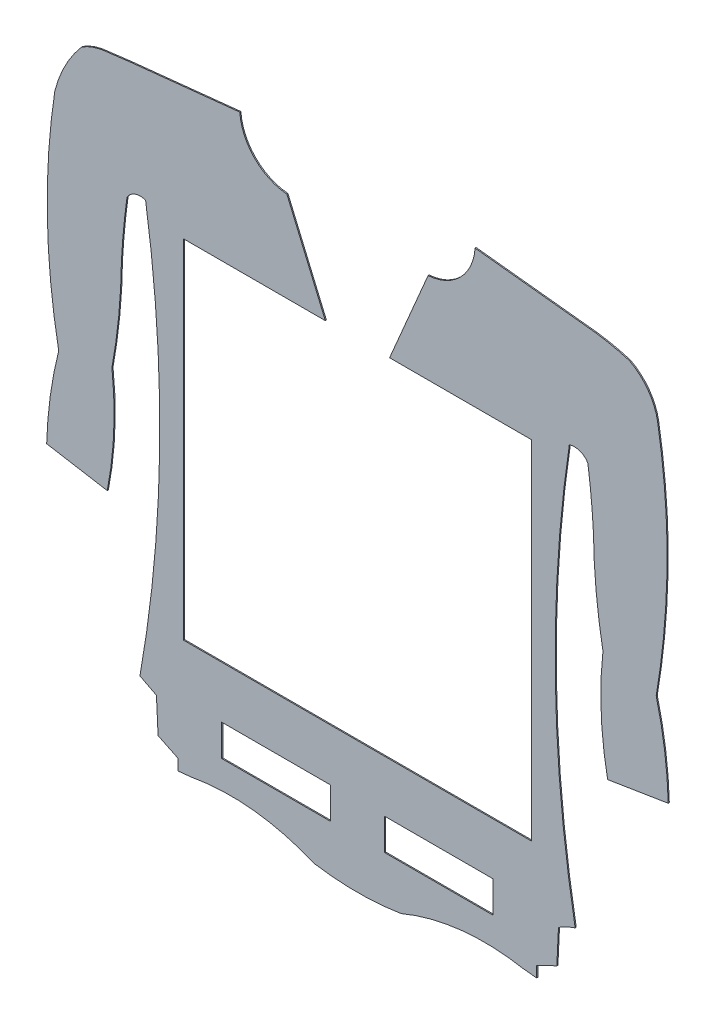
from build123d import *

# Parameters (mm, degrees)
MODEL_W                 = 10
MODEL_H                 = 2.9
SALIENTE_EXTRUIR1_DEPTH = 0.1


with BuildPart() as part:
    # Model → Saliente-Extruir1 (new body)
    with BuildSketch(Plane.XY):
        with BuildLine():
            Line((35.788328911, 21.707483708), (34.562799173, 21.581308157))
            Line((34.562799173, 21.581308157), (34.562652828, 22.581308147))
            Line((34.562652828, 22.581308147), (32.70612679, 23.481266233))
            Line((32.70612679, 23.481266233), (32.556235076, 26.619326304))
            Line((32.556235076, 26.619326304), (31.036614796, 27.404548337))
            ThreePointArc((31.036614796, 27.404548337), (32.854753025, 46.472842043), (31.55872141, 65.583722544))
            ThreePointArc((31.55872141, 65.583722544), (30.590969531, 65.595574241), (29.845859092, 64.977921752))
            ThreePointArc((29.845859092, 64.977921752), (29.533169752, 62.324588377), (29.332558898, 59.660435997))
            ThreePointArc((29.332558898, 59.660435997), (29.087424273, 55.159098423), (28.459158768, 50.695085274))
            ThreePointArc((28.459158768, 50.695085274), (28.627310402, 45.667965845), (28.027763798, 40.673894501))
            Line((28.027763798, 40.673894501), (22.450336553, 41.621102944))
            ThreePointArc((22.450336553, 41.621102944), (22.785375557, 45.632918576), (23.55872141, 49.583722544))
            ThreePointArc((23.55872141, 49.583722544), (22.508827615, 59.842451026), (23.202312308, 70.131419197))
            ThreePointArc((23.202312308, 70.131419197), (24.161095869, 72.639029062), (25.666362665, 74.861987681))
            ThreePointArc((25.666362665, 74.861987681), (26.473042164, 75.27855447), (27.341750173, 75.542384144))
            Line((27.341750173, 75.542384144), (27.561102277, 75.584512547))
            Line((27.561102277, 75.584512547), (30.155444554, 75.902266174))
            Line((30.155444554, 75.902266174), (40.23046228, 76.952955231))
            ThreePointArc((40.23046228, 76.952955231), (41.577753061, 73.95916021), (44.55872141, 72.583722544))
            Line((44.55872141, 72.583722544), (48.101813752, 64.261756561))
            Line((48.101813752, 64.261756561), (35.059978867, 64.261756561))
            Line((35.059978867, 64.261756561), (35.059978867, 32.261756561))
            Line((35.059978867, 32.261756561), (67.059978867, 32.261756561))
            Line((67.059978867, 32.261756561), (67.059978867, 64.261756561))
            Line((67.059978867, 64.261756561), (54.018143983, 64.261756561))
            Line((54.018143983, 64.261756561), (57.561236324, 72.583722544))
            ThreePointArc((57.561236324, 72.583722544), (60.537265907, 73.954182145), (61.888562624, 76.938961663))
            Line((61.888562624, 76.938961663), (73.033030733, 75.731471954))
            ThreePointArc((73.033030733, 75.731471954), (74.577070762, 75.460810441), (76.095189277, 75.070127146))
            ThreePointArc((76.095189277, 75.070127146), (77.804128562, 73.593895905), (78.689246297, 71.516325509))
            ThreePointArc((78.689246297, 71.516325509), (79.299082123, 66.847407918), (79.563217831, 62.146245983))
            ThreePointArc((79.563217831, 62.146245983), (79.348252658, 55.842170985), (78.561236324, 49.583722544))
            ThreePointArc((78.561236324, 49.583722544), (79.338265829, 45.606384219), (79.67109964, 41.567545691))
            Line((79.67109964, 41.567545691), (74.092351811, 40.669243886))
            ThreePointArc((74.092351811, 40.669243886), (73.494321928, 45.665313622), (73.659828166, 50.694325476))
            ThreePointArc((73.659828166, 50.694325476), (73.032031827, 55.158739267), (72.787398837, 59.660435997))
            ThreePointArc((72.787398837, 59.660435997), (72.586787983, 62.324588377), (72.274098643, 64.977921752))
            ThreePointArc((72.274098643, 64.977921752), (71.528988204, 65.595574241), (70.561236324, 65.583722544))
            ThreePointArc((70.561236324, 65.583722544), (69.272286317, 46.443233149), (71.102210852, 27.346869554))
            ThreePointArc((71.102210852, 27.346869554), (70.310817444, 27.032315031), (69.5645482, 26.622034286))
            Line((69.5645482, 26.622034286), (69.415115725, 23.483952313))
            Line((69.415115725, 23.483952313), (67.55872141, 22.583722544))
            Line((67.55872141, 22.583722544), (67.55872141, 21.583722544))
            Line((67.55872141, 21.583722544), (66.33317322, 21.709718743))
            ThreePointArc((66.33317322, 21.709718743), (60.608385736, 21.918148973), (55.064572652, 20.474967974))
            ThreePointArc((55.064572652, 20.474967974), (51.060864546, 20.157739519), (47.057110058, 20.47438205))
            ThreePointArc((47.057110058, 20.47438205), (41.513085831, 21.916751726), (35.788328911, 21.707483708))
        make_face()
        with Locations((58.559978867, 26.033722544)):
            Rectangle(MODEL_W, MODEL_H, mode=Mode.SUBTRACT)
        with Locations((43.559978867, 26.033722544)):
            Rectangle(MODEL_W, MODEL_H, mode=Mode.SUBTRACT)
    extrude(amount=SALIENTE_EXTRUIR1_DEPTH)


solid = part.part
